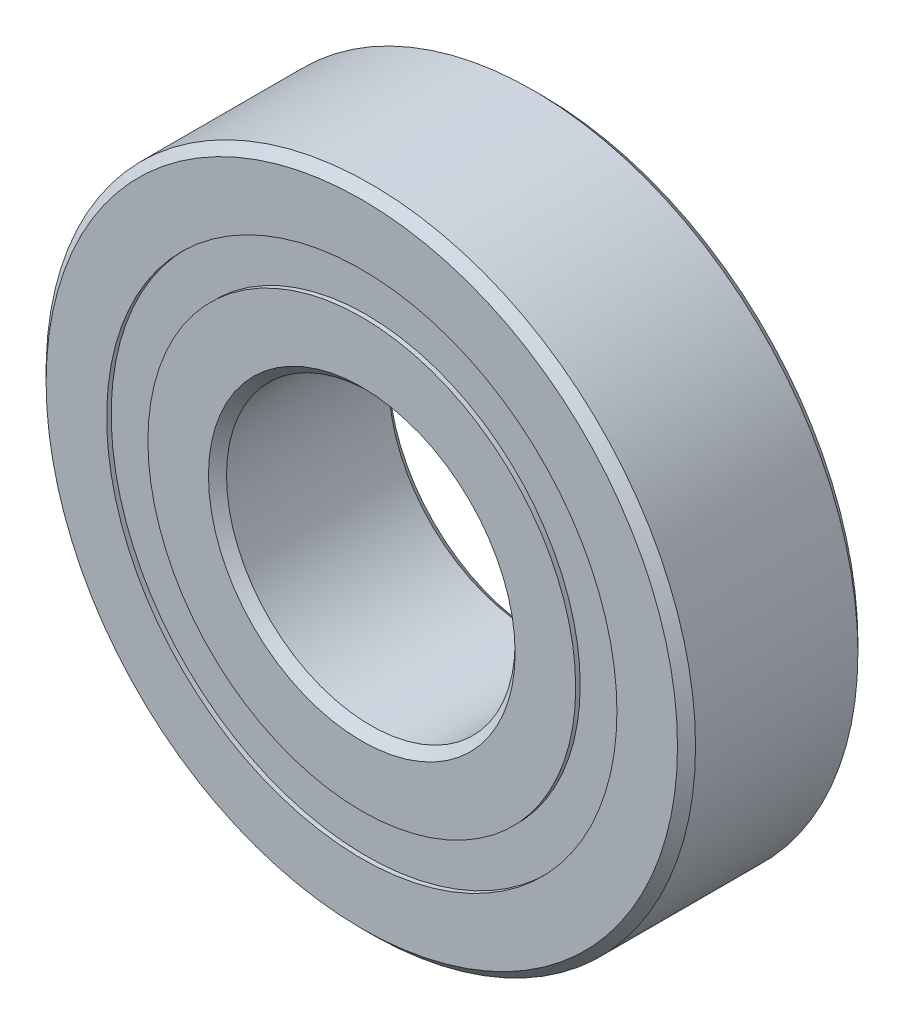
from build123d import *

# Parameters (mm, degrees)
CIRPATTERN1_COUNT = 10
SKETCH5_W         = 1.786827644
SKETCH5_H         = 1.814285714


with BuildPart() as part:
    # Sketch1 → Revolve1 (revolve)
    with BuildSketch(Plane(origin=(0, 0, 0), x_dir=(0, 0, -1), z_dir=(1, 0, 0)), mode=Mode.PRIVATE) as revolve1_sk:
        with BuildLine():
            Line((3.571875, 14.2875), (-3.571875, 14.2875))
            Line((-3.571875, 14.2875), (-3.96875, 13.890625))
            Line((-3.96875, 13.890625), (-3.96875, 11.225892857))
            Line((-3.96875, 11.225892857), (-1.763888889, 11.225892857))
            ThreePointArc((-1.763888889, 11.225892857), (0, 12.302234856), (1.763888889, 11.225892857))
            Line((1.763888889, 11.225892857), (3.96875, 11.225892857))
            Line((3.96875, 11.225892857), (3.96875, 13.890625))
            Line((3.96875, 13.890625), (3.571875, 14.2875))
        make_face()
    revolve(revolve1_sk.sketch.rotate(Axis((0, 0, 3.96875), (0, 0, -1)), 90), axis=Axis((0, 0, 3.96875), (0, 0, -1)))  # turned: the seam where the file's is


with BuildPart() as body_2:
    # Sketch3 → Revolve3 (revolve)
    with BuildSketch(Plane(origin=(0, 0, 0), x_dir=(0, 0, -1), z_dir=(1, 0, 0)), mode=Mode.PRIVATE) as revolve3_sk:
        with BuildLine():
            Line((-3.96875, 9.411607143), (-1.763888889, 9.411607143))
            ThreePointArc((-1.763888889, 9.411607143), (0, 8.335265144), (1.763888889, 9.411607143))
            Line((1.763888889, 9.411607143), (3.96875, 9.411607143))
            Line((3.96875, 9.411607143), (3.96875, 6.746875))
            Line((3.96875, 6.746875), (3.571875, 6.35))
            Line((3.571875, 6.35), (-3.571875, 6.35))
            Line((-3.571875, 6.35), (-3.96875, 6.746875))
            Line((-3.96875, 6.746875), (-3.96875, 9.411607143))
        make_face()
    revolve(revolve3_sk.sketch.rotate(Axis((0, 0, 3.96875), (0, 0, -1)), 90), axis=Axis((0, 0, 3.96875), (0, 0, -1)))  # turned: the seam where the file's is


with BuildPart() as body_3:
    # Sketch4 → Revolve4 (revolve)
    with BuildSketch(Plane(origin=(0, 0, 0), x_dir=(0, 0, -1), z_dir=(1, 0, 0))):
        with BuildLine():
            Line((-1.983484856, 10.31875), (1.983484856, 10.31875))
            ThreePointArc((1.983484856, 10.31875), (0, 12.302234856), (-1.983484856, 10.31875))
        make_face()
    revolve(axis=Axis((0, 10.31875, 1.983484856), (0, 0, -1)))


with BuildPart() as cirpattern1_1:
    # CirPattern1: pattern copy
    add(body_3.part.rotate(Axis((0, 0, 0), (0, 0, 1)), 1 * 360 / CIRPATTERN1_COUNT))


with BuildPart() as cirpattern1_2:
    # CirPattern1: pattern copy
    add(body_3.part.rotate(Axis((0, 0, 0), (0, 0, 1)), 2 * 360 / CIRPATTERN1_COUNT))


with BuildPart() as cirpattern1_3:
    # CirPattern1: pattern copy
    add(body_3.part.rotate(Axis((0, 0, 0), (0, 0, 1)), 3 * 360 / CIRPATTERN1_COUNT))


with BuildPart() as cirpattern1_4:
    # CirPattern1: pattern copy
    add(body_3.part.rotate(Axis((0, 0, 0), (0, 0, 1)), 4 * 360 / CIRPATTERN1_COUNT))


with BuildPart() as cirpattern1_5:
    # CirPattern1: pattern copy
    add(body_3.part.rotate(Axis((0, 0, 0), (0, 0, 1)), 5 * 360 / CIRPATTERN1_COUNT))


with BuildPart() as cirpattern1_6:
    # CirPattern1: pattern copy
    add(body_3.part.rotate(Axis((0, 0, 0), (0, 0, 1)), 6 * 360 / CIRPATTERN1_COUNT))


with BuildPart() as cirpattern1_7:
    # CirPattern1: pattern copy
    add(body_3.part.rotate(Axis((0, 0, 0), (0, 0, 1)), 7 * 360 / CIRPATTERN1_COUNT))


with BuildPart() as cirpattern1_8:
    # CirPattern1: pattern copy
    add(body_3.part.rotate(Axis((0, 0, 0), (0, 0, 1)), 8 * 360 / CIRPATTERN1_COUNT))


with BuildPart() as cirpattern1_9:
    # CirPattern1: pattern copy
    add(body_3.part.rotate(Axis((0, 0, 0), (0, 0, 1)), 9 * 360 / CIRPATTERN1_COUNT))


with BuildPart() as body_13:
    # Sketch5 → Revolve5 (revolve)
    with BuildSketch(Plane(origin=(0, 0, 0), x_dir=(0, 0, -1), z_dir=(1, 0, 0)), mode=Mode.PRIVATE) as revolve5_sk:
        with Locations((-2.876898678, 10.31875)):
            Rectangle(SKETCH5_W, SKETCH5_H)
        with Locations((2.876898678, 10.31875)):
            Rectangle(SKETCH5_W, SKETCH5_H)
    revolve(revolve5_sk.sketch.rotate(Axis((0, 0, 3.96875), (0, 0, -1)), 90), axis=Axis((0, 0, 3.96875), (0, 0, -1)))  # turned: the seam where the file's is


solid = Compound([part.part, body_2.part, body_3.part, cirpattern1_1.part, cirpattern1_2.part, cirpattern1_3.part, cirpattern1_4.part, cirpattern1_5.part, cirpattern1_6.part, cirpattern1_7.part, cirpattern1_8.part, cirpattern1_9.part, body_13.part])
